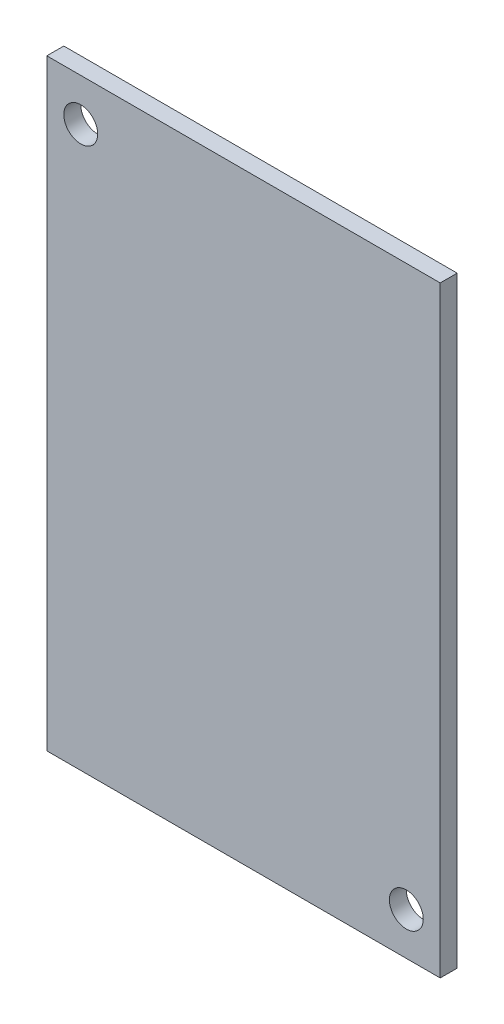
from build123d import *

# Parameters (mm, degrees)
ESQUISSE1_W             = 46.4
ESQUISSE1_H             = 71
EXTRUSION1_DEPTH        = 2
ESQUISSE2_R             = 2
ENL_V_MAT_EXTRU_1_DEPTH = 3


with BuildPart() as part:
    # Esquisse1 → Extrusion1 (new body)
    with BuildSketch(Plane.XY):
        Rectangle(ESQUISSE1_W, ESQUISSE1_H)
    extrude(amount=EXTRUSION1_DEPTH)

    # Esquisse2 → Enlèv. mat.-Extru.1 (cut, through all)
    with BuildSketch(Plane.XY.offset(2)):
        with Locations((-19.2, 30.5)):
            Circle(ESQUISSE2_R)
        with Locations((19.2, -30.5)):
            Circle(ESQUISSE2_R)
    extrude(amount=-ENL_V_MAT_EXTRU_1_DEPTH, mode=Mode.SUBTRACT)


solid = part.part
